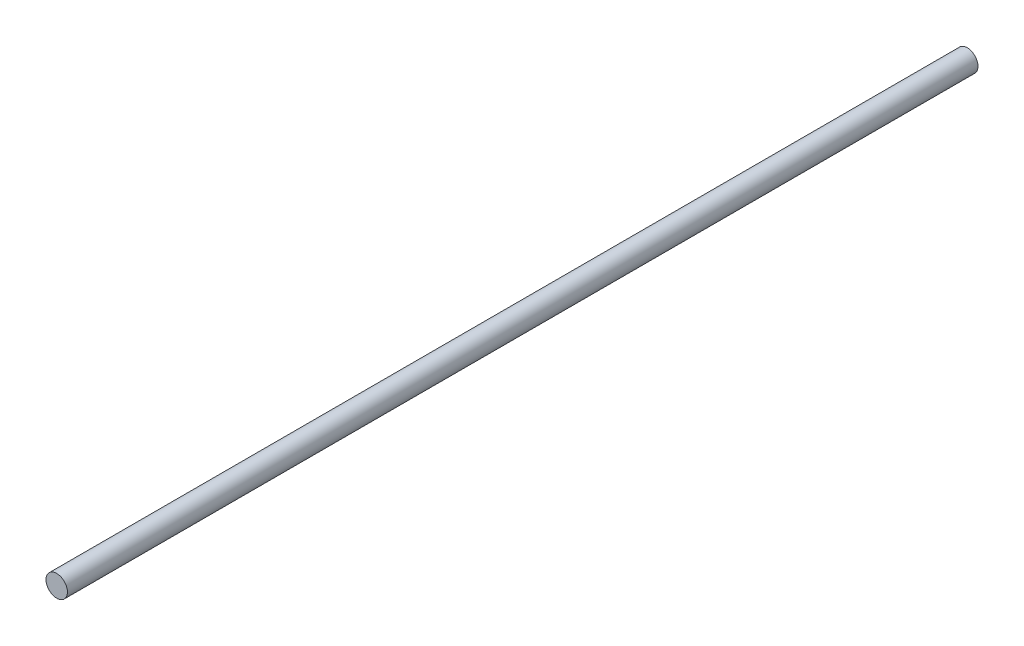
from build123d import *

# Parameters (mm, degrees)
SKETCH1_R           = 6
BOSS_EXTRUDE1_DEPTH = 509.05


with BuildPart() as part:
    # Sketch1 → Boss-Extrude1 (new body)
    with BuildSketch(Plane.XY):
        Circle(SKETCH1_R)
    extrude(amount=BOSS_EXTRUDE1_DEPTH)


solid = part.part
